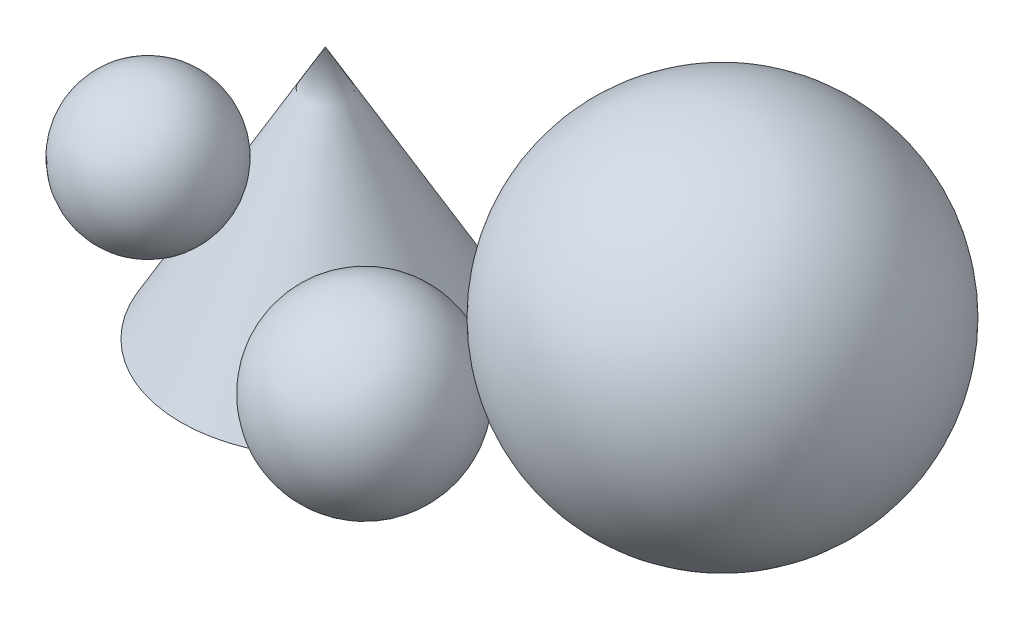
from build123d import *


with BuildPart() as part:
    # Sketch1 → Revolve1 (revolve)
    with BuildSketch(Plane.XY, mode=Mode.PRIVATE) as revolve1_sk:
        Polygon((0, 0), (-40, 70), (-40, 0), align=None)
    revolve(revolve1_sk.sketch.rotate(Axis((-40, 70, 0), (0, -1, 0)), 270), axis=Axis((-40, 70, 0), (0, -1, 0)))  # turned: the seam where the file's is


with BuildPart() as body_2:
    # Sketch3 → Revolve2 (revolve)
    with BuildSketch(Plane.XY.offset(-10)):
        with BuildLine():
            Line((59.772695496, 99.999870832), (60, 0))
            ThreePointArc((60, 0), (109.886218433, 50.113652105), (59.772695496, 99.999870832))
        make_face()
    revolve(axis=Axis((59.772695496, 99.999870832, -10), (0.002273042, -0.999997417, 0)))


with BuildPart() as body_3:
    # Sketch6 → Revolve3 (revolve)
    with BuildSketch(Plane(origin=(0, 25, 0), x_dir=(-1, 0, 0), z_dir=(0, 1, 0))):
        with BuildLine():
            Line((-3.567273263, 57.75700955), (-3.567273263, 7.75700955))
            ThreePointArc((-3.567273263, 7.75700955), (21.432726737, 32.75700955), (-3.567273263, 57.75700955))
        make_face()
    revolve(axis=Axis((3.567273263, 25, 57.75700955), (0, 0, -1)))


with BuildPart() as body_4:
    # Sketch8 → Revolve4 (revolve)
    with BuildSketch(Plane(origin=(-27.692307692, 0, -18.461538462), x_dir=(-0.554700196, 0, 0.832050294), z_dir=(-0.832050294, 0, -0.554700196))):
        with BuildLine():
            Line((57.580627069, 68.374205107), (57.580627069, 28.374205107))
            ThreePointArc((57.580627069, 28.374205107), (37.580627069, 48.374205107), (57.580627069, 68.374205107))
        make_face()
    revolve(axis=Axis((-59.632292826, 68.374205107, 29.448439239), (0, -1, 0)))


solid = Compound([part.part, body_2.part, body_3.part, body_4.part])
